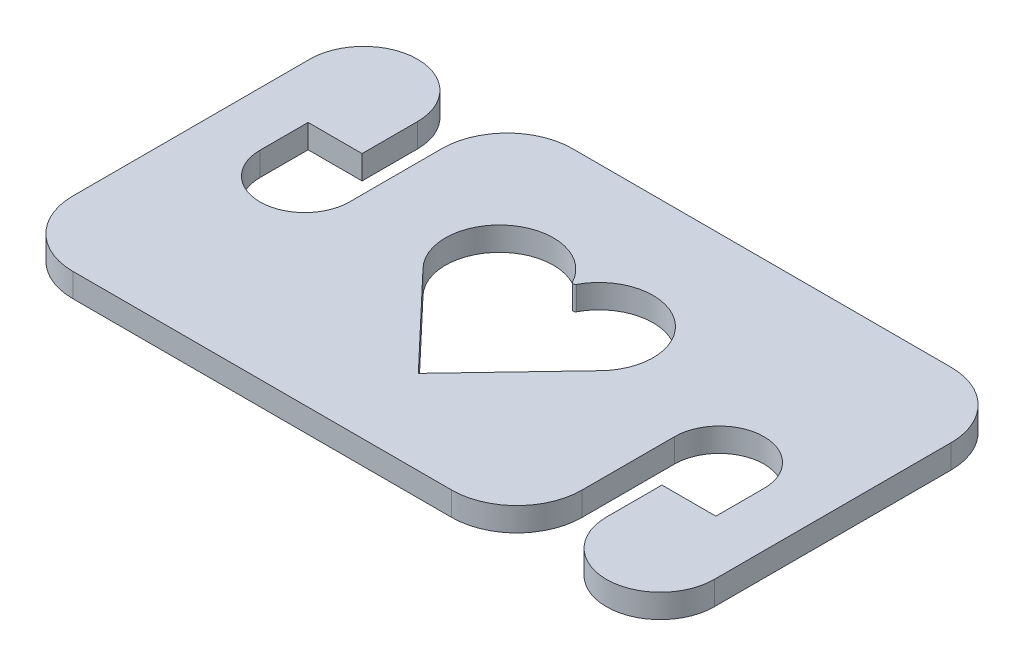
from build123d import *

# Parameters (mm, degrees)
BOSS_EXTRUDE1_DEPTH = 2
CUT_EXTRUDE1_DEPTH  = 3
FILLET1_R           = 0.2


with BuildPart() as part:
    # Sketch2 → Boss-Extrude1 (new body)
    with BuildSketch(Plane(origin=(0, 0, 0), x_dir=(1, 0, 0), z_dir=(0, 1, 0))):
        with BuildLine():
            Line((0, 0.500000092), (0, 20.455103274))
            ThreePointArc((0, 20.455103274), (4.54489668, 25.000000092), (9.089793452, 20.455103365))
            Line((9.089793452, 20.455103365), (9.089793452, 15.776597525))
            Line((9.089793452, 15.776597525), (4.544896726, 15.776597525))
            Line((4.544896726, 15.776597525), (4.544896726, 11.719673062))
            ThreePointArc((4.544896726, 11.719673062), (8.317345089, 7.947224699), (12.089793452, 11.719673062))
            Line((12.089793452, 11.719673062), (12.089793452, 19.500000092))
            ThreePointArc((12.089793452, 19.500000092), (13.700706156, 23.389087388), (17.589793452, 25.000000092))
            Line((17.589793452, 25.000000092), (27.5, 25.000000092))
            Line((27.5, 25.000000092), (49.5, 25.000000092))
            ThreePointArc((49.5, 25.000000092), (53.389087297, 23.389087388), (55, 19.500000092))
            Line((55, 19.500000092), (55, -0.455103091))
            ThreePointArc((55, -0.455103091), (50.45510332, -4.999999908), (45.910206548, -0.455103182))
            Line((45.910206548, -0.455103182), (45.910206548, 4.223402658))
            Line((45.910206548, 4.223402658), (50.455103274, 4.223402658))
            Line((50.455103274, 4.223402658), (50.455103274, 8.280327121))
            ThreePointArc((50.455103274, 8.280327121), (46.682654911, 12.052775484), (42.910206548, 8.280327121))
            Line((42.910206548, 8.280327121), (42.910206548, 0.500000092))
            ThreePointArc((42.910206548, 0.500000092), (41.299293844, -3.389087205), (37.410206548, -4.999999908))
            Line((37.410206548, -4.999999908), (27.5, -4.999999908))
            Line((27.5, -4.999999908), (5.5, -4.999999908))
            ThreePointArc((5.5, -4.999999908), (1.610912703, -3.389087205), (0, 0.500000092))
        make_face()
    extrude(amount=BOSS_EXTRUDE1_DEPTH)

    # Sketch3 → Cut-Extrude1 (cut, through all)
    with BuildSketch(Plane(origin=(0, 2, 0), x_dir=(1, 0, 0), z_dir=(0, 1, 0))):
        with BuildLine():
            Line((27.5, 2.107265014), (20.001901677, 10.000000092))
            ThreePointArc((20.001901677, 10.000000092), (20.810460493, 16.947460398), (27.5, 14.905149634))
            ThreePointArc((27.5, 14.905149634), (34.189539507, 16.947460398), (34.998098323, 10.000000092))
            Line((34.998098323, 10.000000092), (27.5, 2.107265014))
        make_face()
    extrude(amount=-CUT_EXTRUDE1_DEPTH, mode=Mode.SUBTRACT)

    # Fillet1
    fillet1_edges = [part.edges().sort_by_distance(p)[0] for p in [
        (27.5, 1, -14.905149634),
    ]]
    fillet(fillet1_edges, radius=FILLET1_R)


solid = part.part
